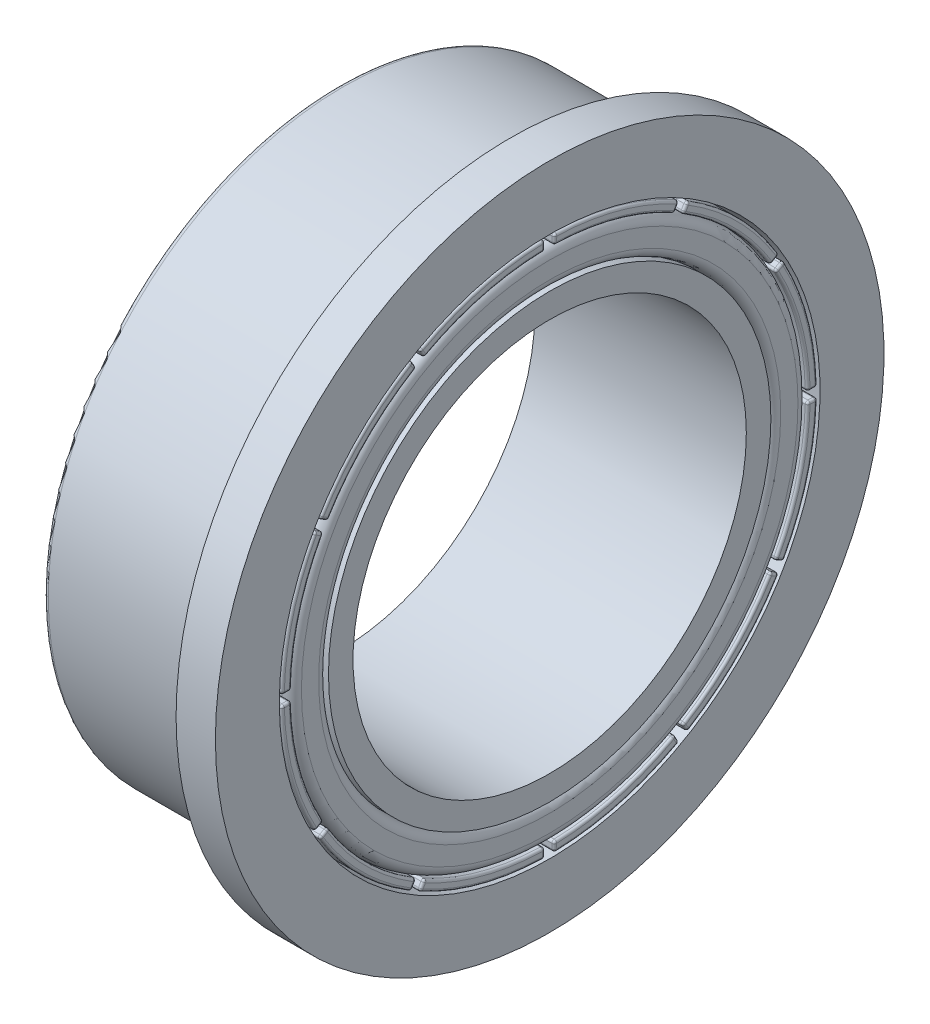
from build123d import *

# Parameters (mm, degrees)
SKETCH_5_R               = 5.25
SKETCH_5_R_2             = 4.5
EXTRUDE_4_DEPTH          = 4.3
FILLET_2_R               = 0.2
SKETCH_3_R               = 4.5
SKETCH_3_R_2             = 4
EXTRUDE_5_DEPTH          = 4.3
EXTRUDE_7_DEPTH          = 4.3
FILLET_6_R               = 0.05
PATTERN_CIRCULAR_7_COUNT = 12
FILLET_7_R               = 0.1


with BuildPart() as part:
    # 草图1 → 旋转1 (revolve)
    with BuildSketch(Plane.XY):
        Polygon((-2.1, 5.5), (2.2, 5.5), (2.2, 6.8), (1.4, 6.8), (1.4, 6), (-2.1, 6), align=None)
    revolve(axis=Axis((-6.9125, 0, 0), (1, 0, 0)))

    # 圆角7
    fillet_7_edges = [part.edges().sort_by_distance(p)[0] for p in [
        (-2.1, -6, 0),
    ]]
    fillet(fillet_7_edges, radius=FILLET_7_R)


with BuildPart() as body_2:
    # 草图5 → 凸台-拉伸4 (new body)
    with BuildSketch(Plane(origin=(2.2, 0, 0), x_dir=(0, 0, -1), z_dir=(1, 0, 0))):
        Circle(SKETCH_5_R)
        Circle(SKETCH_5_R_2, mode=Mode.SUBTRACT)
    extrude(amount=-EXTRUDE_4_DEPTH)

    # 圆角2
    fillet_2_edges = [body_2.edges().sort_by_distance(p)[0] for p in [
        (-2.1, 0, 4.5),
        (-2.1, 0, 5.25),
        (2.2, 0, 4.5),
        (2.2, 0, 5.25),
    ]]
    fillet(fillet_2_edges, radius=FILLET_2_R)

    # 草图3 → 凸台-拉伸5 (add)
    with BuildSketch(Plane(origin=(2.2, 0, 0), x_dir=(0, 0, -1), z_dir=(1, 0, 0))):
        Circle(SKETCH_3_R)
        Circle(SKETCH_3_R_2, mode=Mode.SUBTRACT)
    extrude(amount=-EXTRUDE_5_DEPTH)


with BuildPart() as body_3:
    # 草图6 → 凸台-拉伸7 (new body)
    with BuildSketch(Plane(origin=(2.2, 0, 0), x_dir=(0, 0, -1), z_dir=(1, 0, 0))):
        with BuildLine():
            Line((4.591753462, 2.545250506), (4.766677404, 2.64221243))
            ThreePointArc((4.766677404, 2.64221243), (5.264295753, 1.410563796), (5.449169939, 0.095115615))
            Line((5.449169939, 0.095115615), (5.2492004, 0.091625134))
            ThreePointArc((5.2492004, 0.091625134), (5.071110588, 1.358799987), (4.591753462, 2.545250506))
        make_face()
    extrude(amount=-EXTRUDE_7_DEPTH)

    # 圆角6
    fillet_6_edges = [body_3.edges().sort_by_distance(p)[0] for p in [
        (0.05, 2.545250506, -4.591753462),
        (0.05, 2.64221243, -4.766677404),
        (0.05, 0.095115615, -5.449169939),
        (0.05, 0.091625134, -5.2492004),
        (-2.1, 0.093370374, -5.349185169),
        (-2.1, 1.410563796, -5.264295753),
        (-2.1, 2.593731468, -4.679215433),
        (-2.1, 1.358799987, -5.071110588),
        (2.2, 2.593731468, -4.679215433),
        (2.2, 1.410563796, -5.264295753),
        (2.2, 0.093370374, -5.349185169),
        (2.2, 1.358799987, -5.071110588),
    ]]
    fillet(fillet_6_edges, radius=FILLET_6_R)


with BuildPart() as pattern_circular_7_1:
    # 阵列(圆周)7: pattern copy
    add(body_3.part.rotate(Axis((2.2, 0, 0), (-1, 0, 0)), 1 * 360 / PATTERN_CIRCULAR_7_COUNT))


with BuildPart() as pattern_circular_7_2:
    # 阵列(圆周)7: pattern copy
    add(body_3.part.rotate(Axis((2.2, 0, 0), (-1, 0, 0)), 2 * 360 / PATTERN_CIRCULAR_7_COUNT))


with BuildPart() as pattern_circular_7_3:
    # 阵列(圆周)7: pattern copy
    add(body_3.part.rotate(Axis((2.2, 0, 0), (-1, 0, 0)), 3 * 360 / PATTERN_CIRCULAR_7_COUNT))


with BuildPart() as pattern_circular_7_4:
    # 阵列(圆周)7: pattern copy
    add(body_3.part.rotate(Axis((2.2, 0, 0), (-1, 0, 0)), 4 * 360 / PATTERN_CIRCULAR_7_COUNT))


with BuildPart() as pattern_circular_7_5:
    # 阵列(圆周)7: pattern copy
    add(body_3.part.rotate(Axis((2.2, 0, 0), (-1, 0, 0)), 5 * 360 / PATTERN_CIRCULAR_7_COUNT))


with BuildPart() as pattern_circular_7_6:
    # 阵列(圆周)7: pattern copy
    add(body_3.part.rotate(Axis((2.2, 0, 0), (-1, 0, 0)), 6 * 360 / PATTERN_CIRCULAR_7_COUNT))


with BuildPart() as pattern_circular_7_7:
    # 阵列(圆周)7: pattern copy
    add(body_3.part.rotate(Axis((2.2, 0, 0), (-1, 0, 0)), 7 * 360 / PATTERN_CIRCULAR_7_COUNT))


with BuildPart() as pattern_circular_7_8:
    # 阵列(圆周)7: pattern copy
    add(body_3.part.rotate(Axis((2.2, 0, 0), (-1, 0, 0)), 8 * 360 / PATTERN_CIRCULAR_7_COUNT))


with BuildPart() as pattern_circular_7_9:
    # 阵列(圆周)7: pattern copy
    add(body_3.part.rotate(Axis((2.2, 0, 0), (-1, 0, 0)), 9 * 360 / PATTERN_CIRCULAR_7_COUNT))


with BuildPart() as pattern_circular_7_10:
    # 阵列(圆周)7: pattern copy
    add(body_3.part.rotate(Axis((2.2, 0, 0), (-1, 0, 0)), 10 * 360 / PATTERN_CIRCULAR_7_COUNT))


with BuildPart() as pattern_circular_7_11:
    # 阵列(圆周)7: pattern copy
    add(body_3.part.rotate(Axis((2.2, 0, 0), (-1, 0, 0)), 11 * 360 / PATTERN_CIRCULAR_7_COUNT))


solid = Compound([part.part, body_2.part, body_3.part, pattern_circular_7_1.part, pattern_circular_7_2.part, pattern_circular_7_3.part, pattern_circular_7_4.part, pattern_circular_7_5.part, pattern_circular_7_6.part, pattern_circular_7_7.part, pattern_circular_7_8.part, pattern_circular_7_9.part, pattern_circular_7_10.part, pattern_circular_7_11.part])
